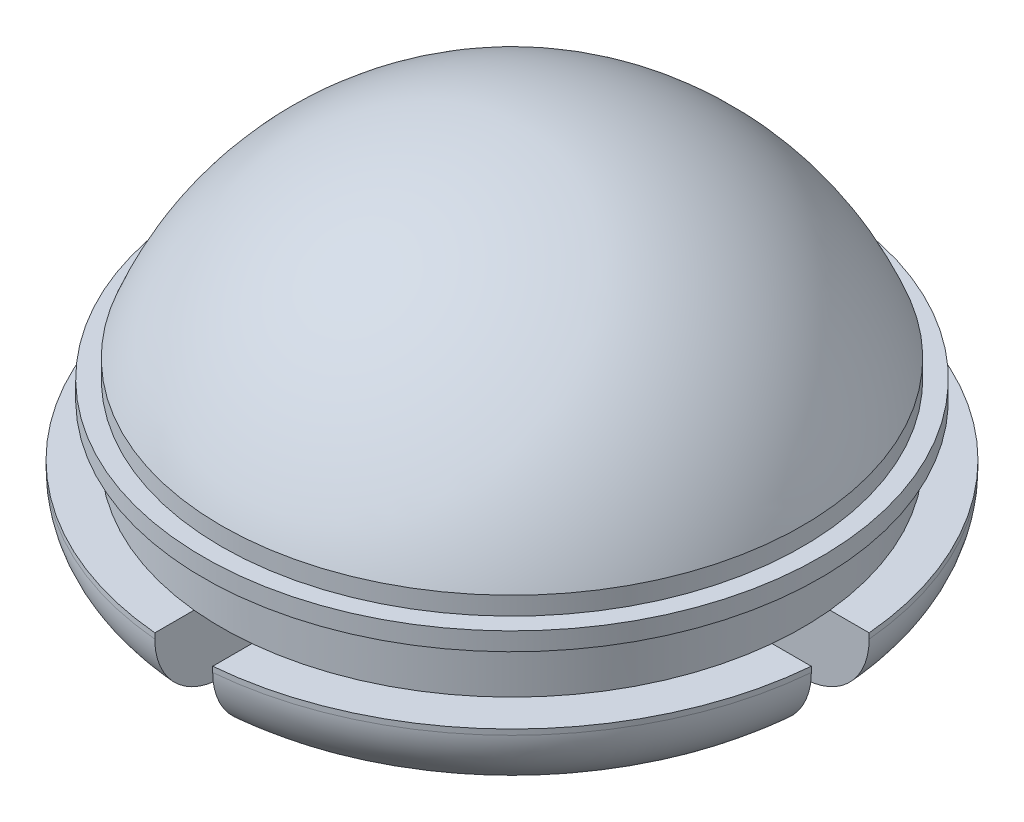
from build123d import *

# Parameters (mm, degrees)
CUT_EXTRUDE1_DEPTH = 2


with BuildPart() as part:
    # Sketch1 → Revolve1 (revolve)
    with BuildSketch(Plane.XY):
        with BuildLine():
            Line((-8.03, -5.559658131), (-8.03, -6.059658131))
            Line((-8.03, -6.059658131), (-8.53, -6.059658131))
            Line((-8.53, -6.059658131), (-8.53, -6.559658131))
            Line((-8.53, -6.559658131), (-8.03, -6.559658131))
            Line((-8.03, -6.559658131), (-8.03, -7.999658131))
            Line((-8.03, -7.999658131), (-9.11, -7.999658131))
            Line((-9.11, -7.999658131), (-9.11, -8.149658131))
            ThreePointArc((-9.11, -8.149658131), (-8.568147545, -9.457805676), (-7.26, -9.999658131))
            Line((-7.26, -9.999658131), (-5.86, -9.999658131))
            ThreePointArc((-5.86, -9.999658131), (-5.506446609, -9.853211521), (-5.36, -9.499658131))
            Line((-5.36, -9.499658131), (-5.36, -6.448646775))
            ThreePointArc((-5.36, -6.448646775), (-3.226258547, -3.82454818), (0, -2.809658131))
            Line((0, -2.809658131), (0, 0))
            ThreePointArc((0, 0), (-4.869895021, -1.545075623), (-8.03, -5.559658131))
        make_face()
    revolve(axis=Axis((0, 0, 0), (0, 1, 0)))

    # Sketch2 → Cut-Extrude1 (cut)
    with BuildSketch(Plane.XZ.offset(9.999658131)):
        Polygon((-0.8, 0.8), (-0.8, 10.234490741), (0.8, 10.234490741), (0.8, 0.8), (9.951695547, 0.8), (9.951695547, -0.8), (0.8, -0.8), (0.8, -9.86372154), (-0.8, -9.86372154), (-0.8, -0.8), (-10.717236114, -0.8), (-10.717236114, 0.8), align=None)
    extrude(amount=-CUT_EXTRUDE1_DEPTH, mode=Mode.SUBTRACT)


solid = part.part
